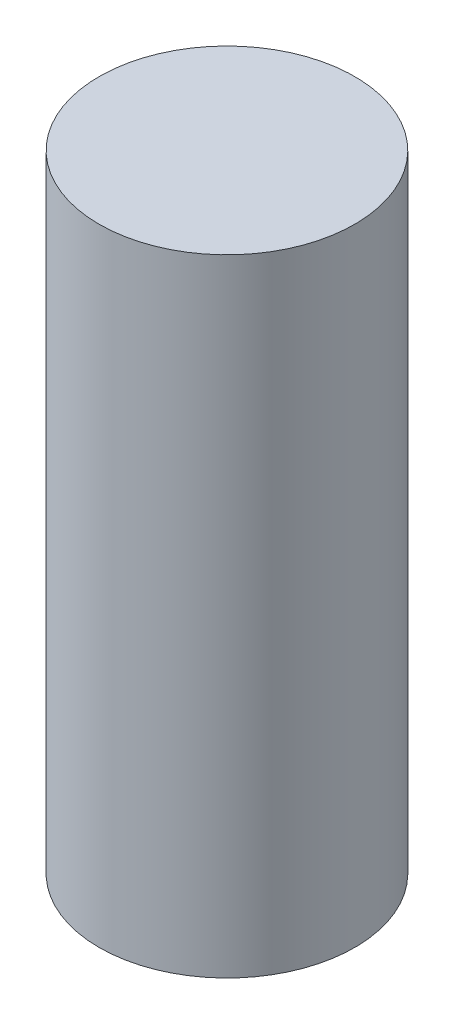
from build123d import *

# Parameters (mm, degrees)
SKETCH1_R           = 2.45
BOSS_EXTRUDE1_DEPTH = 12


with BuildPart() as part:
    # Sketch1 → Boss-Extrude1 (new body)
    with BuildSketch(Plane(origin=(0, 0, 0), x_dir=(1, 0, 0), z_dir=(0, 1, 0))):
        Circle(SKETCH1_R)
    extrude(amount=BOSS_EXTRUDE1_DEPTH)


solid = part.part
